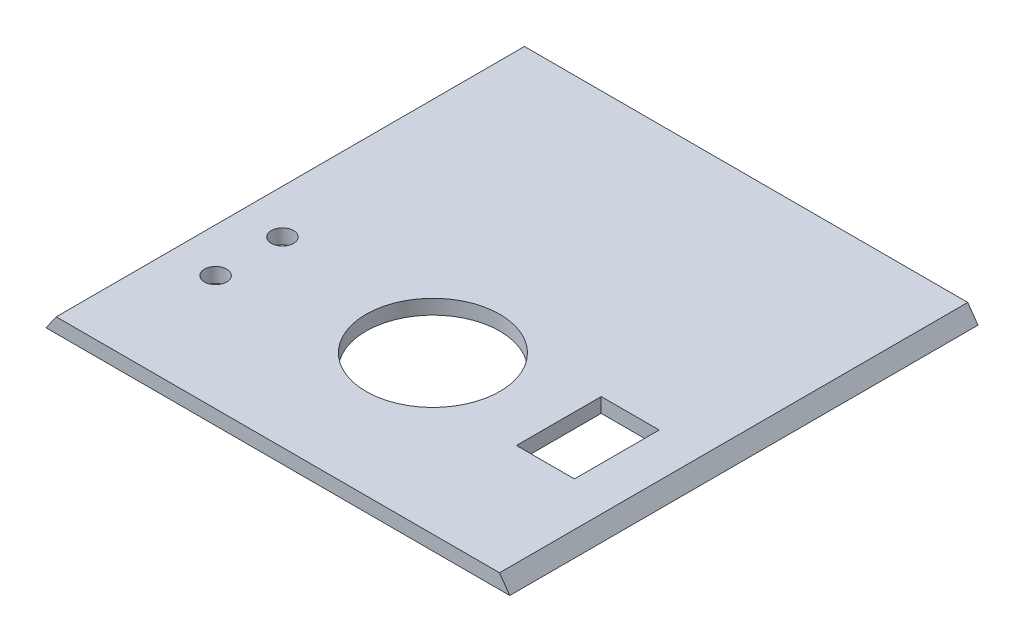
from build123d import *

# Parameters (mm, degrees)
BOSS_EXTRUDE1_DEPTH            = 105
SKETCH2_R                      = 15
CUT_EXTRUDE1_DEPTH             = 1
CUT_EXTRUDE1_DEPTH_BACK        = 4.276608177
CUT_EXTRUDE2_REACH             = 5.277
SKETCH3_R                      = 2.5
CUT_EXTRUDE2_DIRECTION_2_DEPTH = 1
CUT_EXTRUDE3_REACH             = 5.277
SKETCH4_W                      = 13
SKETCH4_H                      = 19


with BuildPart() as part:
    # Sketch1 → Boss-Extrude1 (new body)
    with BuildSketch(Plane.XY):
        Polygon((-48.168421053, -4.926315789), (55.831578947, -4.926315789), (53.537273202, -1.649707612), (-45.874115307, -1.649707612), align=None)
    extrude(amount=-BOSS_EXTRUDE1_DEPTH)

    # Sketch2 → Cut-Extrude1 (cut, two sides)
    with BuildSketch(Plane(origin=(0, -1.649707612, 0), x_dir=(1, 0, 0), z_dir=(0, 1, 0))) as cut_extrude1_sk:
        with Locations((3.362524977, 35.234526985)):
            Circle(SKETCH2_R)
    extrude(amount=CUT_EXTRUDE1_DEPTH, mode=Mode.SUBTRACT)
    extrude(cut_extrude1_sk.sketch, amount=-CUT_EXTRUDE1_DEPTH_BACK, mode=Mode.SUBTRACT)

    # Sketch3 → Cut-Extrude2 (cut, up to next)
    with BuildSketch(Plane(origin=(0, -1.649707612, 0), x_dir=(1, 0, 0), z_dir=(0, 1, 0)), mode=Mode.PRIVATE) as cut_extrude2_sk1:
        with Locations((-36.016928445, 25.875156143)):
            Circle(SKETCH3_R)
    cut_extrude2_tool1 = extrude(cut_extrude2_sk1.sketch, amount=-CUT_EXTRUDE2_REACH, mode=Mode.PRIVATE) & part.part
    add(cut_extrude2_tool1.solids().sort_by_distance((-36.016928, -1.649708, -25.875156))[0], mode=Mode.SUBTRACT)
    # Sketch3 → Cut-Extrude2 (cut, up to next)
    with BuildSketch(Plane(origin=(0, -1.649707612, 0), x_dir=(1, 0, 0), z_dir=(0, 1, 0)), mode=Mode.PRIVATE) as cut_extrude2_sk2:
        with Locations((-36.016928445, 40.875156143)):
            Circle(SKETCH3_R)
    cut_extrude2_tool2 = extrude(cut_extrude2_sk2.sketch, amount=-CUT_EXTRUDE2_REACH, mode=Mode.PRIVATE) & part.part
    add(cut_extrude2_tool2.solids().sort_by_distance((-36.016928, -1.649708, -40.875156))[0], mode=Mode.SUBTRACT)

    # Sketch3 → Cut-Extrude2 direction 2 (cut)
    with BuildSketch(Plane(origin=(0, -1.649707612, 0), x_dir=(1, 0, 0), z_dir=(0, 1, 0))):
        with Locations((-36.016928445, 25.875156143)):
            Circle(SKETCH3_R)
        with Locations((-36.016928445, 40.875156143)):
            Circle(SKETCH3_R)
    extrude(amount=CUT_EXTRUDE2_DIRECTION_2_DEPTH, mode=Mode.SUBTRACT)

    # Sketch4 → Cut-Extrude3 (cut, up to next)
    with BuildSketch(Plane(origin=(0, -1.649707612, 0), x_dir=(1, 0, 0), z_dir=(0, 1, 0)), mode=Mode.PRIVATE) as cut_extrude3_sk1:
        with Locations((37.21482517, 36.119420448)):
            Rectangle(SKETCH4_W, SKETCH4_H)
    cut_extrude3_tool1 = extrude(cut_extrude3_sk1.sketch, amount=-CUT_EXTRUDE3_REACH, mode=Mode.PRIVATE) & part.part
    add(cut_extrude3_tool1.solids().sort_by_distance((37.214825, -1.649708, -36.11942))[0], mode=Mode.SUBTRACT)


solid = part.part
